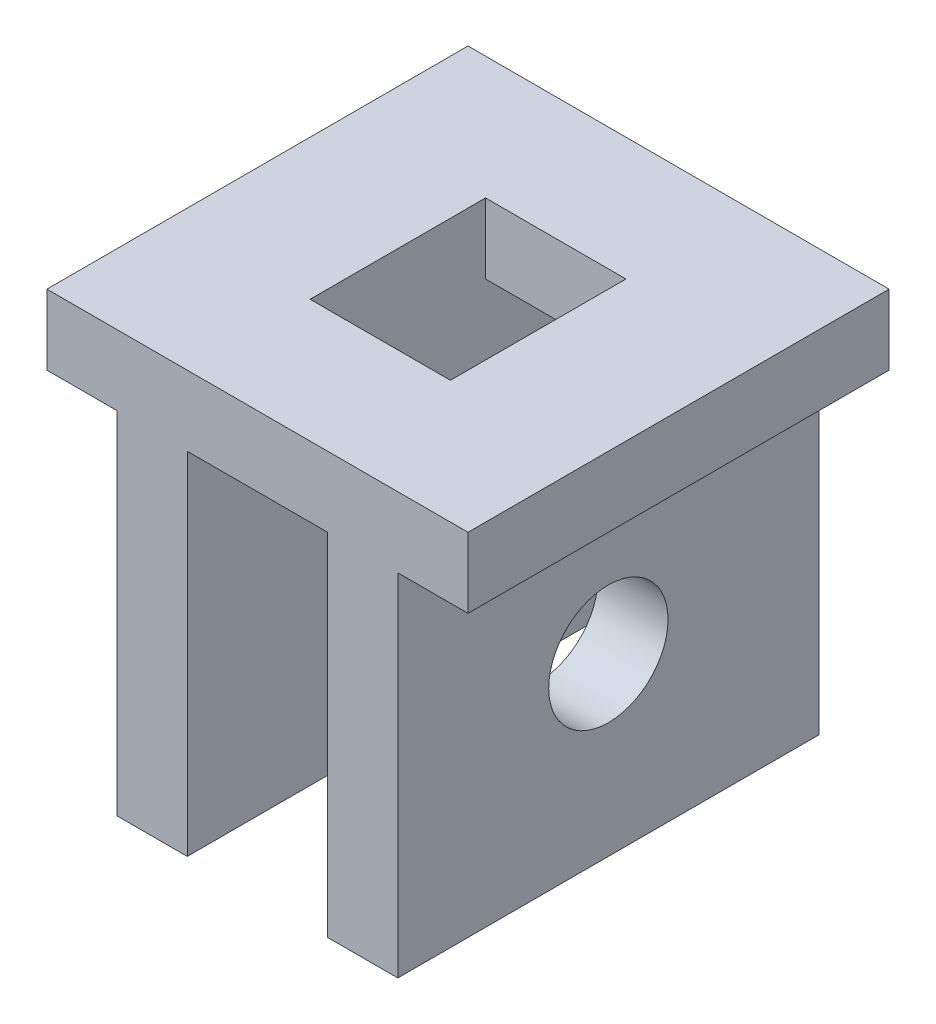
from build123d import *

# Parameters (mm, degrees)
SKETCH2_W               = 3
SKETCH2_H               = 3
BOSS_EXTRUDE1_DEPTH     = 3
SKETCH3_W               = 1
SKETCH3_H               = 3
SKETCH3_W_2             = 0.5
CUT_EXTRUDE1_DEPTH      = 2.5
CUT_EXTRUDE2_DEPTH      = 5.924428901
CUT_EXTRUDE2_DEPTH_BACK = 5.924428901
SKETCH5_R               = 0.425
CUT_EXTRUDE3_DEPTH      = 6.196152423
CUT_EXTRUDE3_DEPTH_BACK = 6.196152423
SKETCH6_W               = 1
SKETCH6_H               = 1.25


with BuildPart() as part:
    # Sketch2 → Boss-Extrude1 (new body)
    with BuildSketch(Plane(origin=(0, 0, 0), x_dir=(1, 0, 0), z_dir=(0, 1, 0))):
        with Locations((-1.5, 1.5)):
            Rectangle(SKETCH2_W, SKETCH2_H)
    extrude(amount=BOSS_EXTRUDE1_DEPTH)

    # Sketch3 → Cut-Extrude1 (cut)
    with BuildSketch(Plane(origin=(0, 0, 0), x_dir=(-1, 0, 0), z_dir=(0, -1, 0))):
        with Locations((1.5, 1.5)):
            Rectangle(SKETCH3_W, SKETCH3_H)
        with Locations((0.25, 1.5)):
            Rectangle(SKETCH3_W_2, SKETCH3_H)
        with Locations((2.75, 1.5)):
            Rectangle(SKETCH3_W_2, SKETCH3_H)
    extrude(amount=-CUT_EXTRUDE1_DEPTH, mode=Mode.SUBTRACT)

    # Sketch5 → Cut-Extrude2 (cut, two sides: drawn at the far end of the back side and taken through both)
    with BuildSketch(Plane(origin=(-0.5, 0, 0), x_dir=(0, 0, -1), z_dir=(1, 0, 0)).offset(-CUT_EXTRUDE2_DEPTH_BACK)):
        with Locations((1.5, 1.25)):
            Circle(SKETCH5_R)
    extrude(amount=CUT_EXTRUDE2_DEPTH + CUT_EXTRUDE2_DEPTH_BACK, mode=Mode.SUBTRACT)

    # Sketch6 → Cut-Extrude3 (cut, two sides: drawn at the far end of the back side and taken through both)
    with BuildSketch(Plane(origin=(0, 3, 0), x_dir=(1, 0, 0), z_dir=(0, 1, 0)).offset(-CUT_EXTRUDE3_DEPTH_BACK)):
        with Locations((-1.5, 1.5)):
            Rectangle(SKETCH6_W, SKETCH6_H)
    extrude(amount=CUT_EXTRUDE3_DEPTH + CUT_EXTRUDE3_DEPTH_BACK, mode=Mode.SUBTRACT)


solid = part.part
